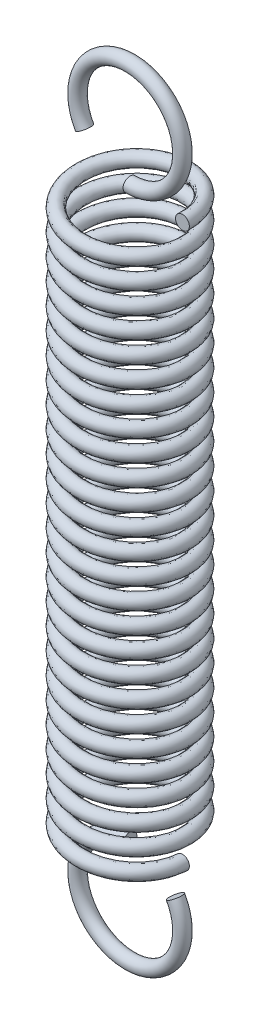
from build123d import *

# Parameters (mm, degrees)
SWEEP1_PITCH       = 1.076923077
SWEEP1_HEIGHT      = 28
SWEEP1_RADIUS      = 2.65
SWEEP1_START_ANGLE = 90
SKETCH3_R          = 0.35
SKETCH4_R          = 0.35
REVOLVE1_ANGLE     = 300
SKETCH7_R          = 0.35
REVOLVE2_ANGLE     = 300


with BuildPart() as part:
    # Sweep1: sweep along a helix
    with BuildLine() as sweep1_path:
        add(Helix(SWEEP1_PITCH, SWEEP1_HEIGHT, SWEEP1_RADIUS, center=(0, 0, 0), direction=(0, 1, 0), lefthand=True, mode=Mode.PRIVATE).rotate(Axis((0, 0, 0), (0, 1, 0)), SWEEP1_START_ANGLE))
    # Sketch3 → Sweep1 (sweep)
    with BuildSketch(Plane.XY):
        with Locations((2.65, 0)):
            Circle(SKETCH3_R)
    sweep(path=sweep1_path.line, is_frenet=True)


with BuildPart() as body_2:
    # Sketch4 → Revolve1 (revolve)
    with BuildSketch(Plane(origin=(0, 0, 0), x_dir=(0, 0, -1), z_dir=(1, 0, 0))):
        with Locations((0, -0.35)):
            Circle(SKETCH4_R)
    revolve(axis=Axis((0, -3, 0), (0, 0, 1)), revolution_arc=REVOLVE1_ANGLE)


with BuildPart() as body_3:
    # Sketch7 → Revolve2 (revolve)
    with BuildSketch(Plane(origin=(0, 0, 0), x_dir=(0, 0, -1), z_dir=(1, 0, 0))):
        with Locations((0, 28.35)):
            Circle(SKETCH7_R)
    revolve(axis=Axis((0, 31, 0), (0, 0, 1)), revolution_arc=REVOLVE2_ANGLE)


solid = Compound([part.part, body_2.part, body_3.part])
